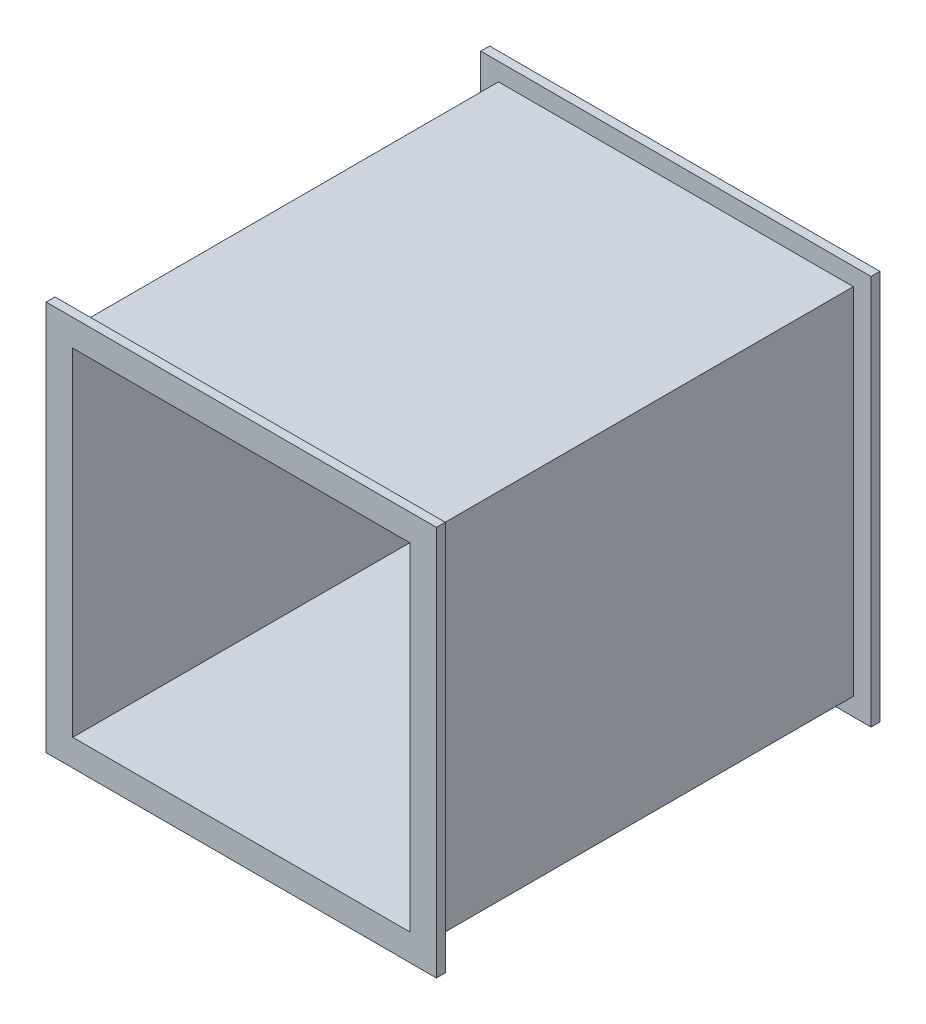
from build123d import *

# Parameters (mm, degrees)
SKETCH1_W           = 200
SKETCH1_H           = 200
BOSS_EXTRUDE1_DEPTH = 250
SKETCH2_W           = 220
SKETCH2_H           = 220
BOSS_EXTRUDE3_DEPTH = 5
SKETCH3_W           = 220
SKETCH3_H           = 220
BOSS_EXTRUDE4_DEPTH = 5
SKETCH4_W           = 190
SKETCH4_H           = 190
CUT_EXTRUDE1_DEPTH  = 251


with BuildPart() as part:
    # Sketch1 → Boss-Extrude1 (new body)
    with BuildSketch(Plane.XY):
        Rectangle(SKETCH1_W, SKETCH1_H)
    extrude(amount=BOSS_EXTRUDE1_DEPTH)

    # Sketch2 → Boss-Extrude3 (add)
    with BuildSketch(Plane.XY.offset(250)):
        Rectangle(SKETCH2_W, SKETCH2_H)
    extrude(amount=-BOSS_EXTRUDE3_DEPTH)

    # Sketch3 → Boss-Extrude4 (add)
    with BuildSketch(Plane(origin=(0, 0, 0), x_dir=(-1, 0, 0), z_dir=(0, 0, -1))):
        Rectangle(SKETCH3_W, SKETCH3_H)
    extrude(amount=-BOSS_EXTRUDE4_DEPTH)

    # Sketch4 → Cut-Extrude1 (cut, through all)
    with BuildSketch(Plane.XY.offset(250)):
        Rectangle(SKETCH4_W, SKETCH4_H)
    extrude(amount=-CUT_EXTRUDE1_DEPTH, mode=Mode.SUBTRACT)


solid = part.part
